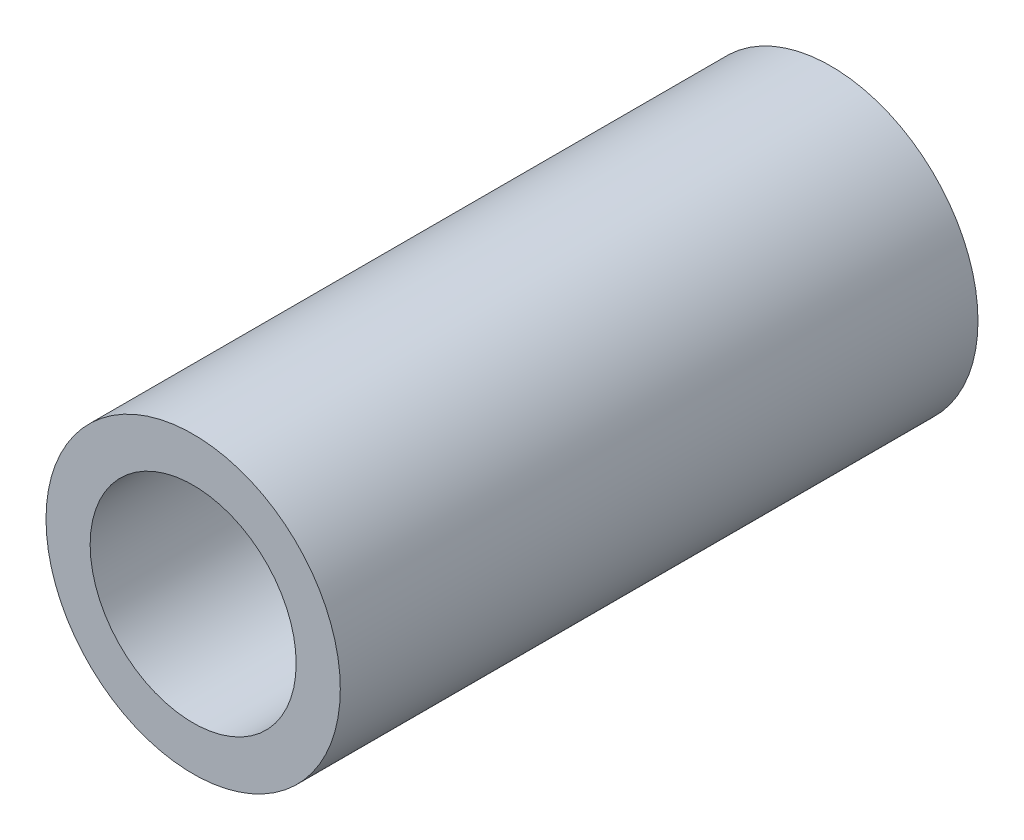
from build123d import *

# Parameters (mm, degrees)
ESBO_O1_R                = 3
ESBO_O1_R_2              = 2.1
RESSALTO_EXTRUS_O1_DEPTH = 13


with BuildPart() as part:
    # Esboço1 → Ressalto-extrusão1 (new body)
    with BuildSketch(Plane.XY):
        Circle(ESBO_O1_R)
        Circle(ESBO_O1_R_2, mode=Mode.SUBTRACT)
    extrude(amount=RESSALTO_EXTRUS_O1_DEPTH)


solid = part.part
